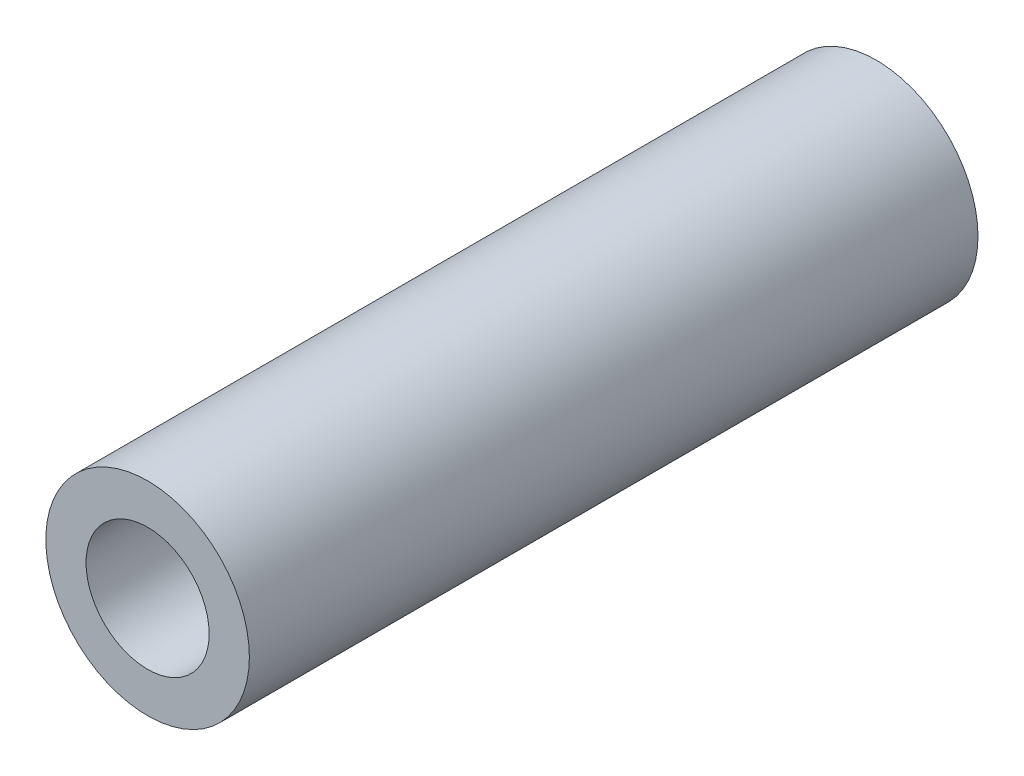
from build123d import *

# Parameters (mm, degrees)
SKETCH1_R           = 4.05
SKETCH1_R_2         = 2.45
BOSS_EXTRUDE1_DEPTH = 29


with BuildPart() as part:
    # Sketch1 → Boss-Extrude1 (new body)
    with BuildSketch(Plane.XY):
        Circle(SKETCH1_R)
        Circle(SKETCH1_R_2, mode=Mode.SUBTRACT)
    extrude(amount=BOSS_EXTRUDE1_DEPTH)


solid = part.part
